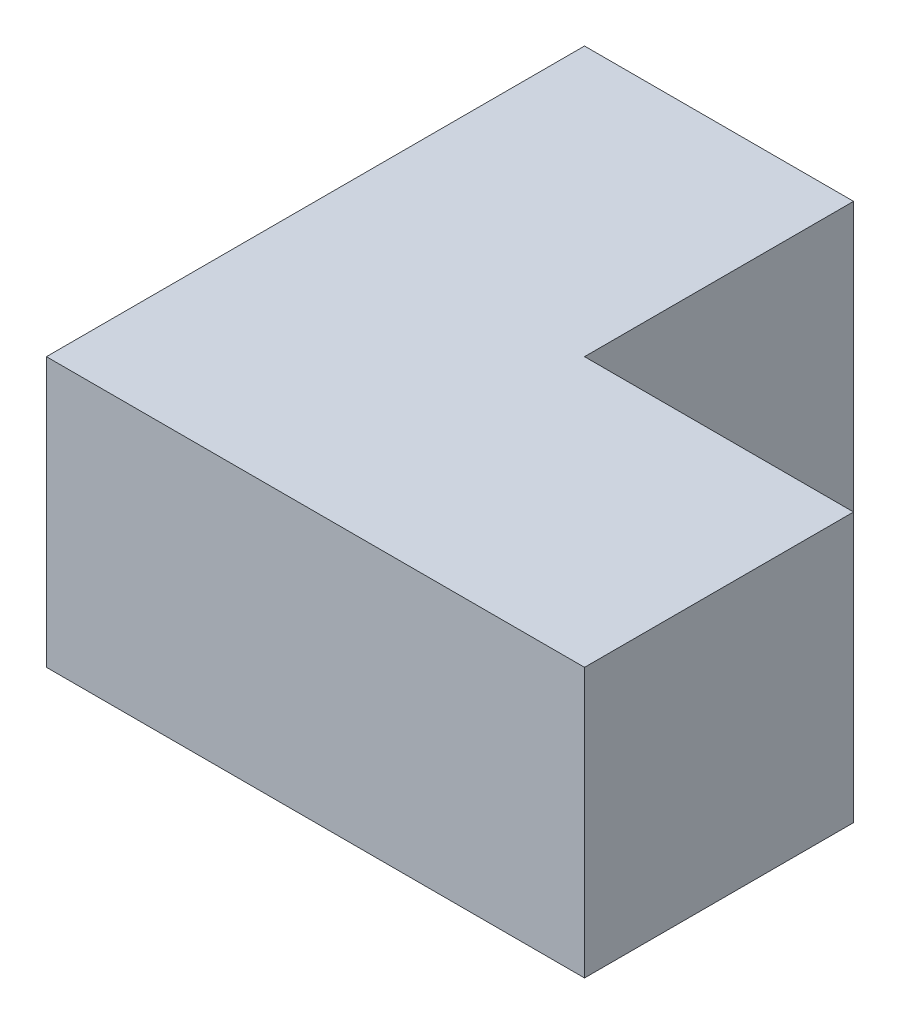
from build123d import *

# Parameters (mm, degrees)
BOSS_EXTRUDE1_DEPTH = 25.4


with BuildPart() as part:
    # Sketch1 → Boss-Extrude1 (new body)
    with BuildSketch(Plane(origin=(0, 0, 0), x_dir=(1, 0, 0), z_dir=(0, 1, 0))):
        Polygon((-88.214075935, 50.8), (-62.814075935, 50.8), (-62.814075935, 25.4), (-37.414075935, 25.4), (-37.414075935, 0), (-88.214075935, 0), align=None)
    extrude(amount=BOSS_EXTRUDE1_DEPTH)


solid = part.part
